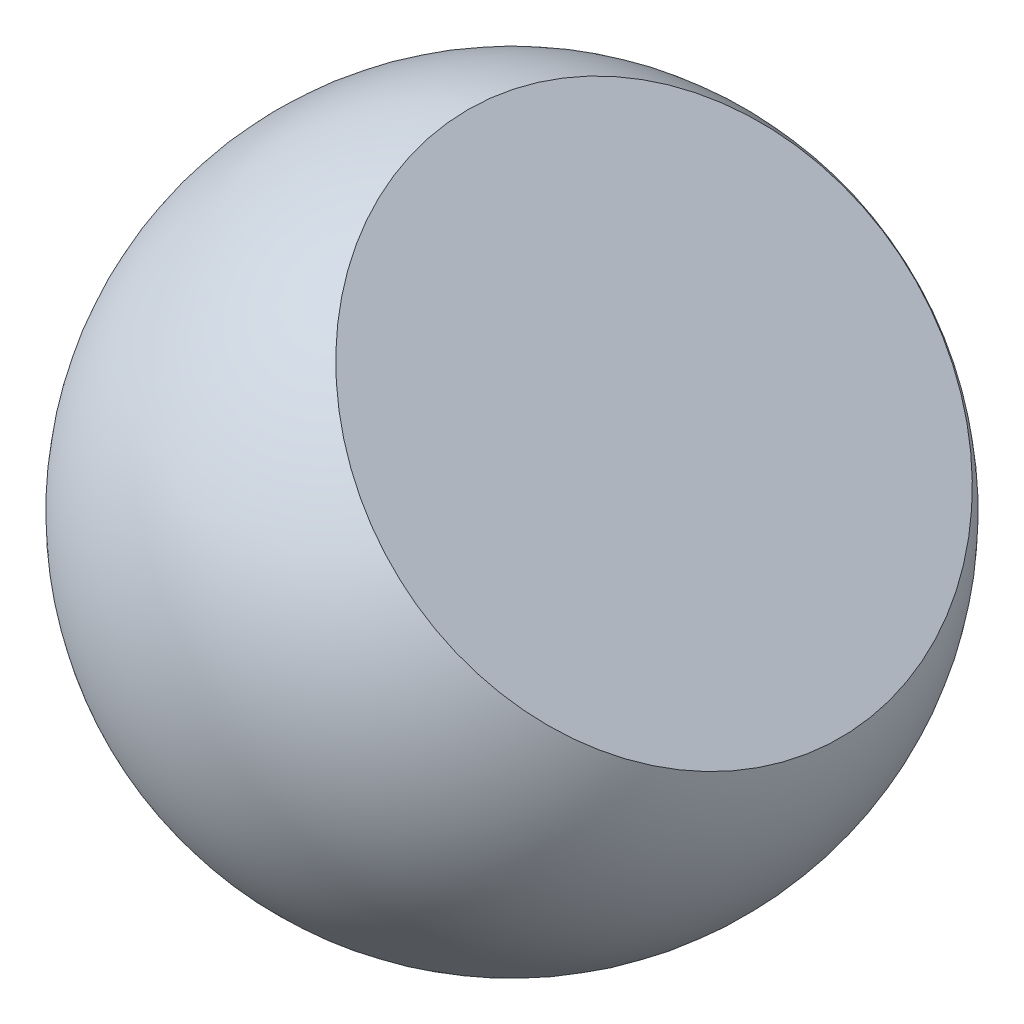
from build123d import *


with BuildPart() as part:
    # Sketch2 → Revolve1 (revolve)
    with BuildSketch(Plane(origin=(0, 0, 0), x_dir=(1, 0, 0), z_dir=(0, 1, 0))):
        with BuildLine():
            Line((-381, 0), (381, 0))
            ThreePointArc((381, 0), (0, 381), (-381, 0))
        make_face()
    revolve(axis=Axis((-381, 0, 0), (1, 0, 0)))

    # SurfaceCut1
    split(bisect_by=Plane(origin=(164.227634794, 170.588907734, 0), x_dir=(-0.7204112876391361, 0.6935470976380205, 0), z_dir=(0.6935470976380205, 0.7204112876391361, 0)), keep=Keep.BOTTOM)


solid = part.part
